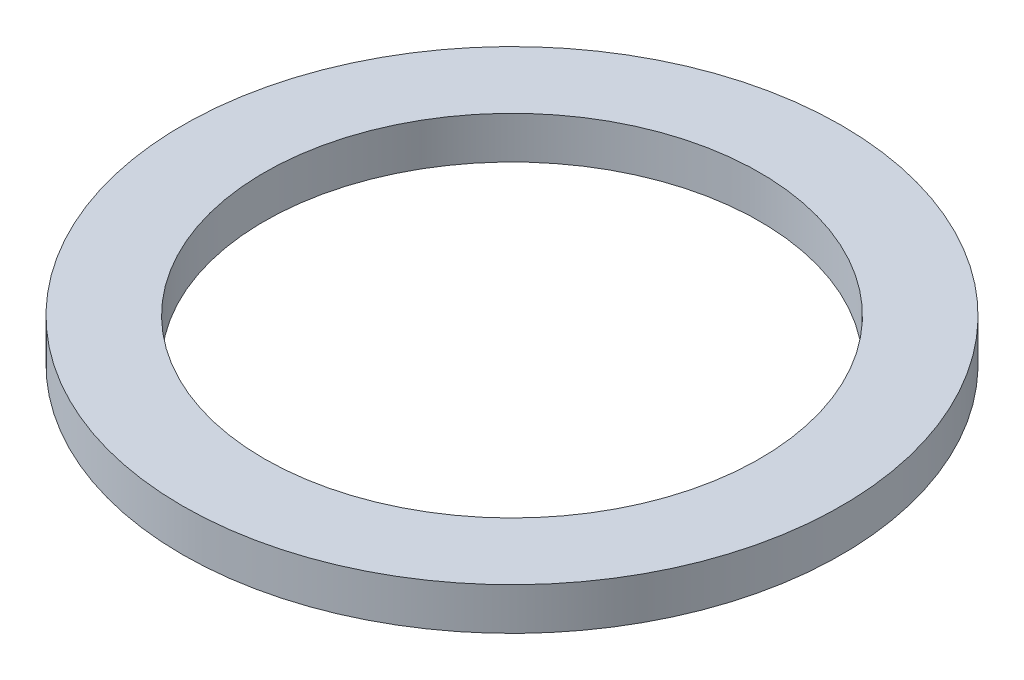
from build123d import *

# Parameters (mm, degrees)
SKETCH1_R           = 3.175
SKETCH1_R_2         = 2.3876
BOSS_EXTRUDE1_DEPTH = 0.4064


with BuildPart() as part:
    # Sketch1 → Boss-Extrude1 (new body)
    with BuildSketch(Plane(origin=(0, 0, 0), x_dir=(1, 0, 0), z_dir=(0, 1, 0))):
        Circle(SKETCH1_R)
        Circle(SKETCH1_R_2, mode=Mode.SUBTRACT)
    extrude(amount=BOSS_EXTRUDE1_DEPTH)


solid = part.part
